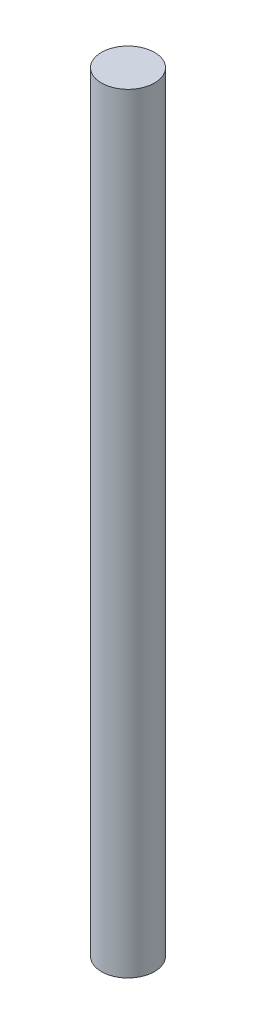
from build123d import *

# Parameters (mm, degrees)
SKETCH1_R           = 6.35
BOSS_EXTRUDE1_DEPTH = 184.15


with BuildPart() as part:
    # Sketch1 → Boss-Extrude1 (new body)
    with BuildSketch(Plane(origin=(0, 0, 0), x_dir=(1, 0, 0), z_dir=(0, 1, 0))):
        Circle(SKETCH1_R)
    extrude(amount=BOSS_EXTRUDE1_DEPTH)


solid = part.part
